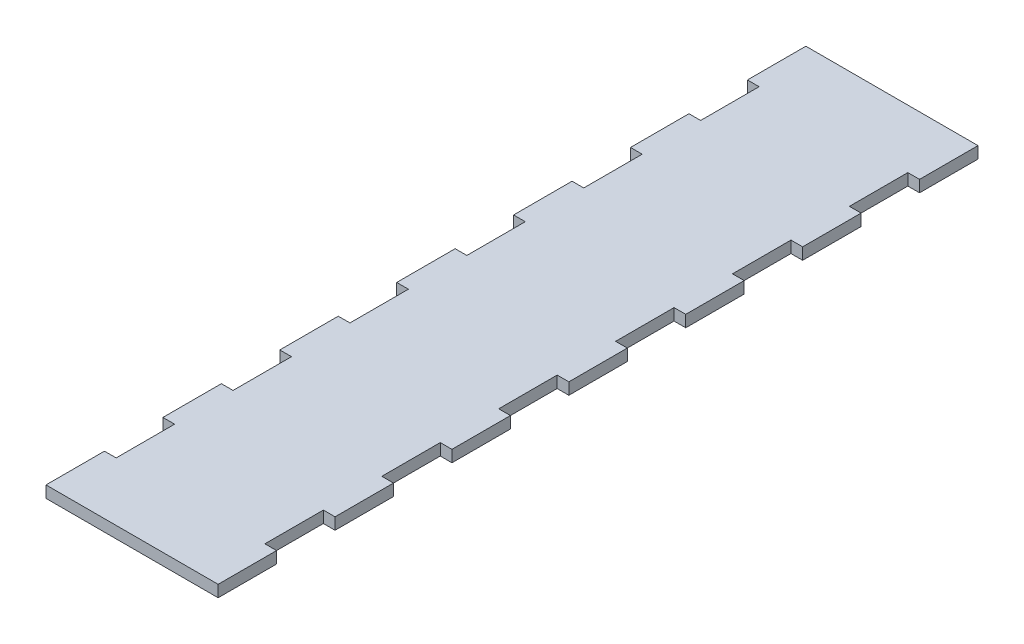
from build123d import *

# Parameters (mm, degrees)
EXTRUDE_1_DEPTH = 4


with BuildPart() as part:
    # Эскиз1 → Бобышка-Вытянуть1 (new body)
    with BuildSketch(Plane(origin=(0, 0, 0), x_dir=(1, 0, 0), z_dir=(0, 1, 0))):
        Polygon((-29.45, -40), (-29.45, -60), (-25.45, -60), (-25.45, -80), (-29.45, -80), (-29.45, -100), (-25.45, -100), (-25.45, -120), (-29.45, -120), (-29.45, -140), (-25.45, -140), (-25.45, -160), (-29.45, -160), (-29.45, -180), (-25.45, -180), (-25.45, -200), (-29.45, -200), (-29.45, -220), (-25.45, -220), (-25.45, -240), (-29.45, -240), (-29.45, -260), (29.45, -260), (29.45, -240), (25.45, -240), (25.45, -220), (29.45, -220), (29.45, -200), (25.45, -200), (25.45, -180), (29.45, -180), (29.45, -160), (25.45, -160), (25.45, -140), (29.45, -140), (29.45, -120), (25.45, -120), (25.45, -100), (29.45, -100), (29.45, -80), (25.45, -80), (25.45, -60), (29.45, -60), (29.45, -40), (25.45, -40), (25.45, -20), (29.45, -20), (29.45, 0), (-29.45, 0), (-29.45, -20), (-25.45, -20), (-25.45, -40), align=None)
    extrude(amount=EXTRUDE_1_DEPTH)


solid = part.part
